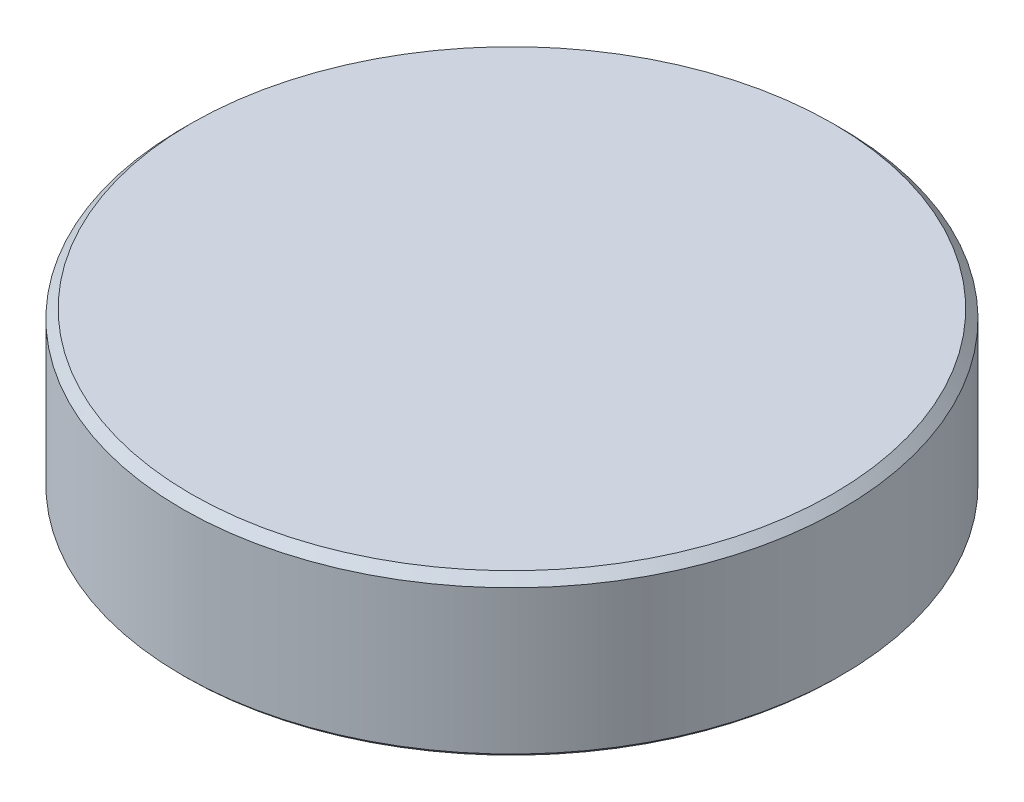
from build123d import *

# Parameters (mm, degrees)
SKETCH1_R           = 38
SKETCH1_R_2         = 36
BOSS_EXTRUDE1_DEPTH = 16
SKETCH2_R           = 38
BOSS_EXTRUDE2_DEPTH = 2
CHAMFER1_SIZE       = 0.4
SKETCH3_R           = 5
BOSS_EXTRUDE3_DEPTH = 2
SKETCH4_R           = 3
BOSS_EXTRUDE4_DEPTH = 7
CHAMFER2_SIZE       = 0.4
CHAMFER3_SIZE       = 1


with BuildPart() as part:
    # Sketch1 → Boss-Extrude1 (new body)
    with BuildSketch(Plane(origin=(0, 0, 0), x_dir=(1, 0, 0), z_dir=(0, 1, 0))):
        Circle(SKETCH1_R)
        Circle(SKETCH1_R_2, mode=Mode.SUBTRACT)
    extrude(amount=BOSS_EXTRUDE1_DEPTH)

    # Sketch2 → Boss-Extrude2 (add)
    with BuildSketch(Plane(origin=(0, 16, 0), x_dir=(1, 0, 0), z_dir=(0, 1, 0))):
        Circle(SKETCH2_R)
    extrude(amount=BOSS_EXTRUDE2_DEPTH)

    # Chamfer1
    chamfer1_edges = [part.edges().sort_by_distance(p)[0] for p in [
        (-36, 16, 0),
        (-38, 0, 0),
        (-36, 0, 0),
    ]]
    chamfer(chamfer1_edges, length=CHAMFER1_SIZE)

    # Sketch3 → Boss-Extrude3 (add)
    with BuildSketch(Plane.XZ.offset(-16)):
        Circle(SKETCH3_R)
    extrude(amount=BOSS_EXTRUDE3_DEPTH)

    # Sketch4 → Boss-Extrude4 (add)
    with BuildSketch(Plane(origin=(0, 14, 0), x_dir=(-1, 0, 0), z_dir=(0, -1, 0))):
        Circle(SKETCH4_R)
    extrude(amount=BOSS_EXTRUDE4_DEPTH)

    # Chamfer2
    chamfer2_edges = [part.edges().sort_by_distance(p)[0] for p in [
        (-5, 16, 0),
        (-5, 14, 0),
        (3, 7, 0),
    ]]
    chamfer(chamfer2_edges, length=CHAMFER2_SIZE)

    # Chamfer3
    chamfer3_edges = [part.edges().sort_by_distance(p)[0] for p in [
        (-38, 18, 0),
    ]]
    chamfer(chamfer3_edges, length=CHAMFER3_SIZE)


solid = part.part
